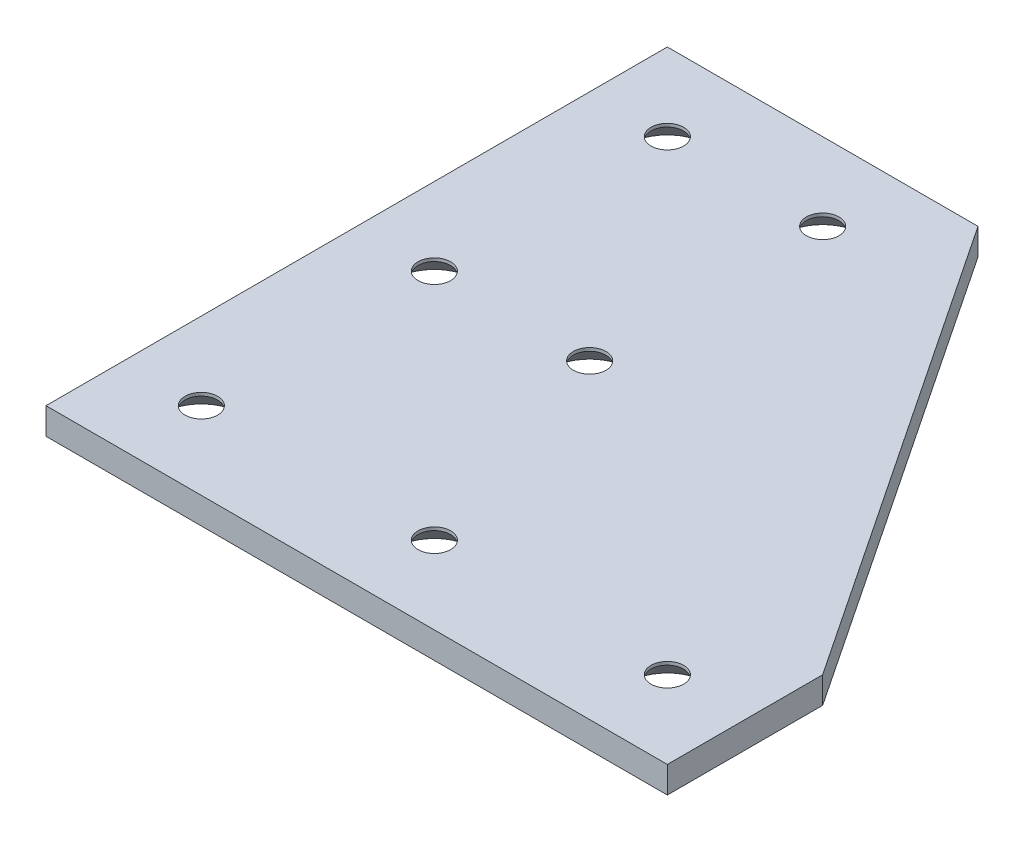
from build123d import *

# Parameters (mm, degrees)
BOSS_EXTRUDE1_DEPTH = 3.416
SKETCH2_R           = 2.1
CUT_EXTRUDE1_DEPTH  = 4
CHAMFER1_SIZE       = 3


with BuildPart() as part:
    # Sketch1 → Boss-Extrude1 (new body)
    with BuildSketch(Plane(origin=(0, 0, 0), x_dir=(1, 0, 0), z_dir=(0, 1, 0))):
        Polygon((0, 0), (80, 0), (80, 20), (40, 80), (0, 80), align=None)
    extrude(amount=BOSS_EXTRUDE1_DEPTH)

    # Sketch2 → Cut-Extrude1 (cut)
    with BuildSketch(Plane(origin=(0, 3.416, 0), x_dir=(1, 0, 0), z_dir=(0, 1, 0))):
        with Locations((10, 10)):
            Circle(SKETCH2_R)
        with Locations((40, 10)):
            Circle(SKETCH2_R)
        with Locations((70, 10)):
            Circle(SKETCH2_R)
        with Locations((30, 40)):
            Circle(SKETCH2_R)
        with Locations((30, 70)):
            Circle(SKETCH2_R)
        with Locations((10, 40)):
            Circle(SKETCH2_R)
        with Locations((10, 70)):
            Circle(SKETCH2_R)
    extrude(amount=-CUT_EXTRUDE1_DEPTH, mode=Mode.SUBTRACT)

    # Chamfer1
    chamfer1_edges = [part.edges().sort_by_distance(p)[0] for p in [
        (7.9, 0, -70),
        (7.9, 0, -40),
        (27.9, 0, -70),
        (27.9, 0, -40),
        (67.9, 0, -10),
        (37.9, 0, -10),
        (7.9, 0, -10),
    ]]
    chamfer(chamfer1_edges, length=CHAMFER1_SIZE)


solid = part.part
